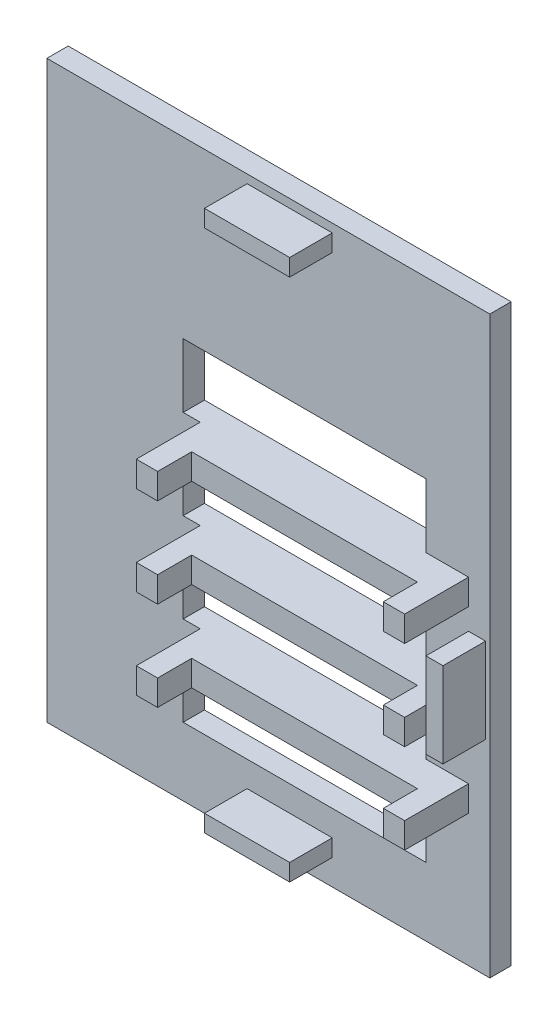
from build123d import *

# Parameters (mm, degrees)
SKETCH_1_W          = 104
SKETCH_1_H          = 135
EXTRUDE_2_DEPTH     = 5
SKETCH_2_W          = 20
SKETCH_2_H          = 4
SKETCH_2_W_2        = 4
SKETCH_2_H_2        = 20
EXTRUDE_3_DEPTH     = 10
CUT_EXTRUDE_1_REACH = 7
SKETCH_3_W          = 57
SKETCH_3_H          = 15
SKETCH_4_W          = 5
SKETCH_4_H          = 6
EXTRUDE_4_DEPTH     = 15
SKETCH_6_W          = 53
SKETCH_6_H          = 6
EXTRUDE_5_DEPTH     = 7


with BuildPart() as part:
    # 草圖1 → 填料-伸長2 (new body)
    with BuildSketch(Plane.XY):
        with Locations((34.103184984, -53.003221767)):
            Rectangle(SKETCH_1_W, SKETCH_1_H)
    extrude(amount=EXTRUDE_2_DEPTH)

    # 草圖2 → 填料-伸長3 (add)
    with BuildSketch(Plane.XY.offset(5)):
        with Locations((39.103184984, 10.496778233)):
            Rectangle(SKETCH_2_W, SKETCH_2_H)
        with Locations((39.103184984, -112.503221767)):
            Rectangle(SKETCH_2_W, SKETCH_2_H)
        with Locations((83.103184984, -62.503221767)):
            Rectangle(SKETCH_2_W_2, SKETCH_2_H_2)
    extrude(amount=EXTRUDE_3_DEPTH)

    # 草圖3 → 除料-伸長1 (cut, up to next)
    with BuildSketch(Plane.XY.offset(5), mode=Mode.PRIVATE) as cut_extrude_1_sk1:
        with Locations((42.603184984, -97.003221767)):
            Rectangle(SKETCH_3_W, SKETCH_3_H)
    cut_extrude_1_tool1 = extrude(cut_extrude_1_sk1.sketch, amount=-CUT_EXTRUDE_1_REACH, mode=Mode.PRIVATE) & part.part
    add(cut_extrude_1_tool1.solids().sort_by_distance((42.603185, -97.003222, 5))[0], mode=Mode.SUBTRACT)
    # 草圖3 → 除料-伸長1 (cut, up to next)
    with BuildSketch(Plane.XY.offset(5), mode=Mode.PRIVATE) as cut_extrude_1_sk2:
        with Locations((42.603184984, -76.003221767)):
            Rectangle(SKETCH_3_W, SKETCH_3_H)
    cut_extrude_1_tool2 = extrude(cut_extrude_1_sk2.sketch, amount=-CUT_EXTRUDE_1_REACH, mode=Mode.PRIVATE) & part.part
    add(cut_extrude_1_tool2.solids().sort_by_distance((42.603185, -76.003222, 5))[0], mode=Mode.SUBTRACT)
    # 草圖3 → 除料-伸長1 (cut, up to next)
    with BuildSketch(Plane.XY.offset(5), mode=Mode.PRIVATE) as cut_extrude_1_sk3:
        with Locations((42.603184984, -55.003221767)):
            Rectangle(SKETCH_3_W, SKETCH_3_H)
    cut_extrude_1_tool3 = extrude(cut_extrude_1_sk3.sketch, amount=-CUT_EXTRUDE_1_REACH, mode=Mode.PRIVATE) & part.part
    add(cut_extrude_1_tool3.solids().sort_by_distance((42.603185, -55.003222, 5))[0], mode=Mode.SUBTRACT)
    # 草圖3 → 除料-伸長1 (cut, up to next)
    with BuildSketch(Plane.XY.offset(5), mode=Mode.PRIVATE) as cut_extrude_1_sk4:
        with Locations((42.603184984, -34.003221767)):
            Rectangle(SKETCH_3_W, SKETCH_3_H)
    cut_extrude_1_tool4 = extrude(cut_extrude_1_sk4.sketch, amount=-CUT_EXTRUDE_1_REACH, mode=Mode.PRIVATE) & part.part
    add(cut_extrude_1_tool4.solids().sort_by_distance((42.603185, -34.003222, 5))[0], mode=Mode.SUBTRACT)

    # 草圖4 → 填料-伸長4 (add)
    with BuildSketch(Plane.XY.offset(5)):
        with Locations((20.603184984, -44.503221767)):
            Rectangle(SKETCH_4_W, SKETCH_4_H)
        with Locations((78.603184984, -44.503221767)):
            Rectangle(SKETCH_4_W, SKETCH_4_H)
        with Locations((20.603184984, -65.503221767)):
            Rectangle(SKETCH_4_W, SKETCH_4_H)
        with Locations((78.603184984, -65.503221767)):
            Rectangle(SKETCH_4_W, SKETCH_4_H)
        with Locations((20.603184984, -86.503221767)):
            Rectangle(SKETCH_4_W, SKETCH_4_H)
        with Locations((78.603184984, -86.503221767)):
            Rectangle(SKETCH_4_W, SKETCH_4_H)
    extrude(amount=EXTRUDE_4_DEPTH)

    # 草圖6 → 填料-伸長5 (add)
    with BuildSketch(Plane.XY.offset(5)):
        with Locations((49.603184984, -44.503221767)):
            Rectangle(SKETCH_6_W, SKETCH_6_H)
        with Locations((49.603184984, -65.503221767)):
            Rectangle(SKETCH_6_W, SKETCH_6_H)
        with Locations((49.603184984, -86.503221767)):
            Rectangle(SKETCH_6_W, SKETCH_6_H)
    extrude(amount=EXTRUDE_5_DEPTH)


solid = part.part
